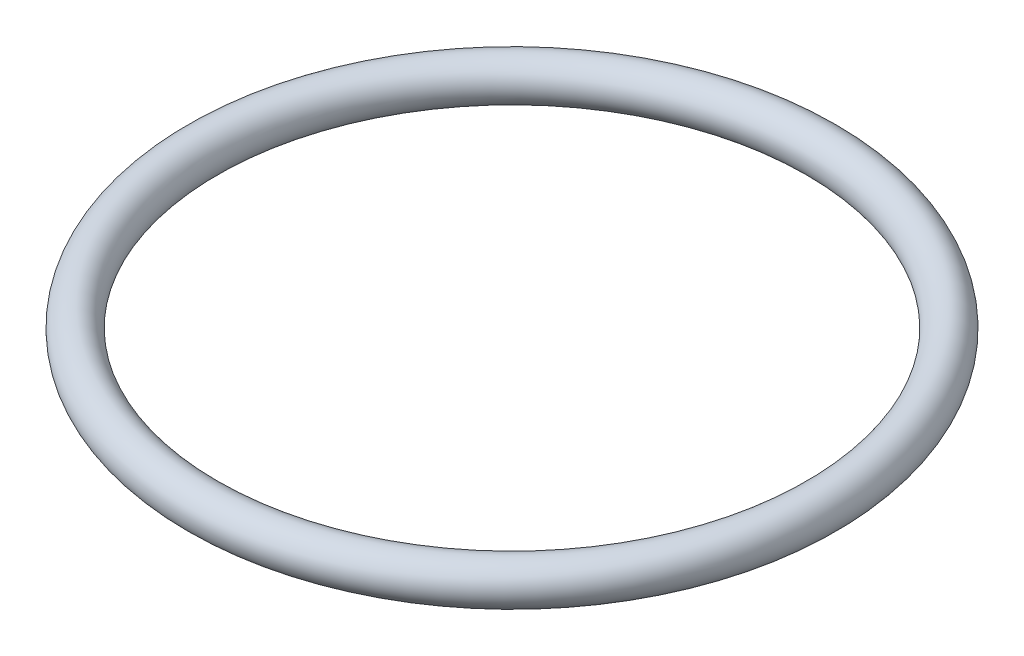
from build123d import *

# Parameters (mm, degrees)
SKETCH1_R = 0.75


with BuildPart() as part:
    # Sketch1 → Revolve1 (revolve)
    with BuildSketch(Plane.XY):
        with Locations((11.25, 0)):
            Circle(SKETCH1_R)
    revolve(axis=Axis((0, 6.978278679, 0), (0, -1, 0)))


solid = part.part
